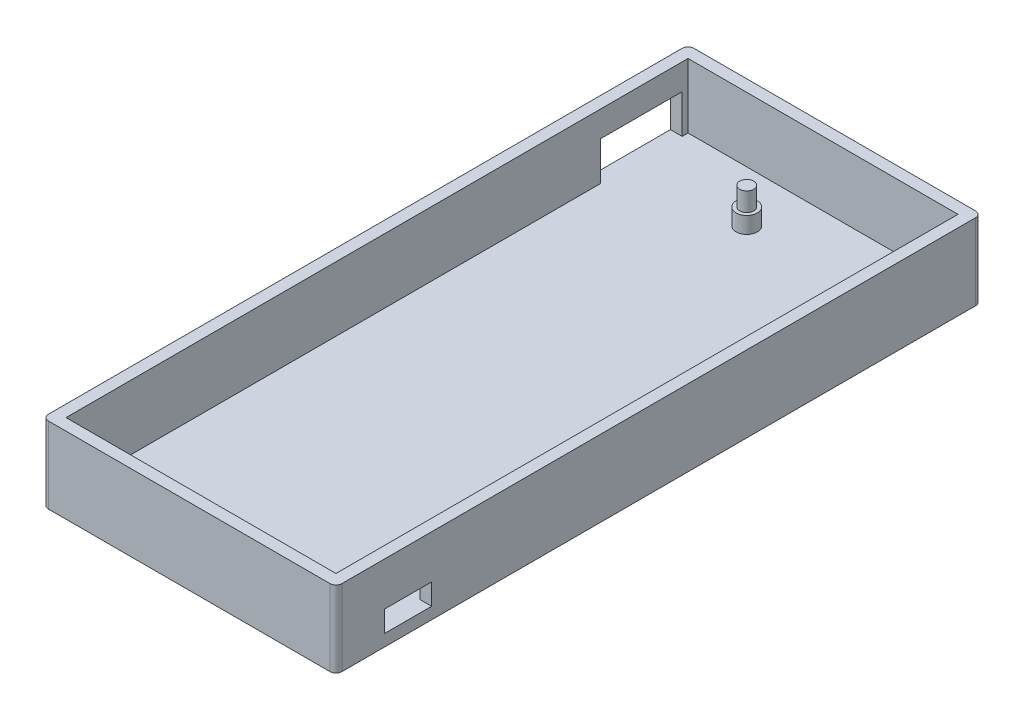
from build123d import *

# Parameters (mm, degrees)
SKETCH1_W               = 50
SKETCH1_H               = 110
BOSS_EXTRUDE1_DEPTH     = 2
SKETCH2_W               = 50
SKETCH2_H               = 110
SKETCH2_W_2             = 46
SKETCH2_H_2             = 106
BOSS_EXTRUDE3_DEPTH     = 11
SKETCH3_R               = 1.2
BOSS_EXTRUDE4_DEPTH     = 11
SKETCH4_W               = 52
SKETCH4_H               = 112
SKETCH4_W_2             = 50
SKETCH4_H_2             = 110
EXTRUDE_THIN1_DEPTH     = 13
FILLET2_R               = 2
EXTRUDE_THIN3_DEPTH     = 3
SKETCH6_R               = 1.8
BOSS_EXTRUDE5_DEPTH     = 2.8
SKETCH8_W               = 8
SKETCH8_H               = 3.6
CUT_EXTRUDE2_DEPTH      = 12.8
SKETCH11_W              = 13.1
SKETCH11_H              = 5.8
CUT_EXTRUDE5_DEPTH      = 3
SKETCH13_W              = 108
SKETCH13_H              = 3
CUT_EXTRUDE6_DEPTH      = 70
CUT_EXTRUDE6_DEPTH_BACK = 40
SKETCH14_W              = 48
SKETCH14_H              = 3
CUT_EXTRUDE7_DEPTH      = 160
CUT_EXTRUDE7_DEPTH_BACK = 40
SKETCH15_W              = 66.867567733
SKETCH15_H              = 122.152543676
CUT_EXTRUDE8_DEPTH      = 40
SKETCH16_W              = 37.40524021
SKETCH16_H              = 102.153015582
CUT_EXTRUDE9_DEPTH      = 5
CUT_EXTRUDE_THIN2_DEPTH = 55
SKETCH18_W              = 13.9
SKETCH18_H              = 6.6
CUT_EXTRUDE10_DEPTH     = 2


with BuildPart() as part:
    # Sketch1 → Boss-Extrude1 (new body)
    with BuildSketch(Plane(origin=(0, 0, 0), x_dir=(1, 0, 0), z_dir=(0, 1, 0))):
        with Locations((-52.022587269, -1.919917864)):
            Rectangle(SKETCH1_W, SKETCH1_H)
    extrude(amount=BOSS_EXTRUDE1_DEPTH)

    # Sketch2 → Boss-Extrude3 (add)
    with BuildSketch(Plane(origin=(0, 2, 0), x_dir=(1, 0, 0), z_dir=(0, 1, 0))):
        with Locations((-52.022587269, -1.919917864)):
            Rectangle(SKETCH2_W, SKETCH2_H)
        with Locations((-52.022587269, -1.919917864)):
            Rectangle(SKETCH2_W_2, SKETCH2_H_2, mode=Mode.SUBTRACT)
    extrude(amount=BOSS_EXTRUDE3_DEPTH)

    # Sketch3 → Boss-Extrude4 (add)
    with BuildSketch(Plane(origin=(0, 2, 0), x_dir=(1, 0, 0), z_dir=(0, 1, 0))):
        with Locations((-31.022587269, 42.380082136)):
            Circle(SKETCH3_R)
        with Locations((-31.022587269, -52.919917864)):
            Circle(SKETCH3_R)
        with Locations((-56.322587269, 42.380082136)):
            Circle(SKETCH3_R)
        with Locations((-56.322587269, -52.919917864)):
            Circle(SKETCH3_R)
    extrude(amount=BOSS_EXTRUDE4_DEPTH)

    # Sketch4 → Extrude-Thin1 (add)
    with BuildSketch(Plane(origin=(0, 13, 0), x_dir=(1, 0, 0), z_dir=(0, 1, 0))):
        with Locations((-52.022587269, -1.919917864)):
            Rectangle(SKETCH4_W, SKETCH4_H)
        with Locations((-52.022587269, -1.919917864)):
            Rectangle(SKETCH4_W_2, SKETCH4_H_2, mode=Mode.SUBTRACT)
    extrude(amount=-EXTRUDE_THIN1_DEPTH)

    # Fillet2
    fillet2_edges = [part.edges().sort_by_distance(p)[0] for p in [
        (-26.022587269, 6.5, -54.080082136),
        (-26.022587269, 6.5, 57.919917864),
        (-78.022587269, 6.5, 57.919917864),
        (-78.022587269, 6.5, -54.080082136),
    ]]
    fillet(fillet2_edges, radius=FILLET2_R)

    # Sketch5 → Extrude-Thin3 (add)
    with BuildSketch(Plane(origin=(0, 13, 0), x_dir=(1, 0, 0), z_dir=(0, 1, 0))):
        with BuildLine():
            Line((-28.022587269, 54.080082136), (-76.022587269, 54.080082136))
            ThreePointArc((-76.022587269, 54.080082136), (-77.436800831, 53.494295698), (-78.022587269, 52.080082136))
            Line((-78.022587269, 52.080082136), (-78.022587269, -55.919917864))
            ThreePointArc((-78.022587269, -55.919917864), (-77.436800831, -57.334131427), (-76.022587269, -57.919917864))
            Line((-76.022587269, -57.919917864), (-28.022587269, -57.919917864))
            ThreePointArc((-28.022587269, -57.919917864), (-26.608373707, -57.334131427), (-26.022587269, -55.919917864))
            Line((-26.022587269, -55.919917864), (-26.022587269, 52.080082136))
            ThreePointArc((-26.022587269, 52.080082136), (-26.608373707, 53.494295698), (-28.022587269, 54.080082136))
        make_face()
        with BuildLine():
            Line((-28.022587269, 52.880082136), (-76.022587269, 52.880082136))
            ThreePointArc((-76.022587269, 52.880082136), (-76.588272694, 52.64576756), (-76.822587269, 52.080082136))
            Line((-76.822587269, 52.080082136), (-76.822587269, -55.919917864))
            ThreePointArc((-76.822587269, -55.919917864), (-76.588272694, -56.485603289), (-76.022587269, -56.719917864))
            Line((-76.022587269, -56.719917864), (-28.022587269, -56.719917864))
            ThreePointArc((-28.022587269, -56.719917864), (-27.456901844, -56.485603289), (-27.222587269, -55.919917864))
            Line((-27.222587269, -55.919917864), (-27.222587269, 52.080082136))
            ThreePointArc((-27.222587269, 52.080082136), (-27.456901844, 52.64576756), (-28.022587269, 52.880082136))
        make_face(mode=Mode.SUBTRACT)
    extrude(amount=EXTRUDE_THIN3_DEPTH)

    # Sketch6 → Boss-Extrude5 (add)
    with BuildSketch(Plane(origin=(0, 2, 0), x_dir=(1, 0, 0), z_dir=(0, 1, 0))):
        with Locations((-56.322587269, -52.919917864)):
            Circle(SKETCH6_R)
        with Locations((-31.022587269, -52.919917864)):
            Circle(SKETCH6_R)
        with Locations((-56.322587269, 42.380082136)):
            Circle(SKETCH6_R)
        with Locations((-31.022587269, 42.380082136)):
            Circle(SKETCH6_R)
    extrude(amount=BOSS_EXTRUDE5_DEPTH)

    # Sketch8 → Cut-Extrude2 (cut)
    with BuildSketch(Plane(origin=(-26.022587269, 0, 0), x_dir=(0, 0, -1), z_dir=(1, 0, 0))):
        with Locations((-44.619917864, 3.8)):
            Rectangle(SKETCH8_W, SKETCH8_H)
    extrude(amount=-CUT_EXTRUDE2_DEPTH, mode=Mode.SUBTRACT)

    # Sketch11 → Cut-Extrude5 (cut)
    with BuildSketch(Plane.ZY.offset(78.022587269)):
        with Locations((-43.530082136, 4.9)):
            Rectangle(SKETCH11_W, SKETCH11_H)
    extrude(amount=-CUT_EXTRUDE5_DEPTH, mode=Mode.SUBTRACT)

    # Sketch13 → Cut-Extrude6 (cut, two sides)
    with BuildSketch(Plane(origin=(-76.822587269, 0, 0), x_dir=(0, 0, -1), z_dir=(1, 0, 0))) as cut_extrude6_sk:
        with Locations((-1.919917864, 14.5)):
            Rectangle(SKETCH13_W, SKETCH13_H)
    extrude(amount=CUT_EXTRUDE6_DEPTH, mode=Mode.SUBTRACT)
    extrude(cut_extrude6_sk.sketch, amount=-CUT_EXTRUDE6_DEPTH_BACK, mode=Mode.SUBTRACT)

    # Sketch14 → Cut-Extrude7 (cut, two sides)
    with BuildSketch(Plane.XY.offset(-52.880082136)) as cut_extrude7_sk:
        with Locations((-52.022587269, 14.5)):
            Rectangle(SKETCH14_W, SKETCH14_H)
    extrude(amount=CUT_EXTRUDE7_DEPTH, mode=Mode.SUBTRACT)
    extrude(cut_extrude7_sk.sketch, amount=-CUT_EXTRUDE7_DEPTH_BACK, mode=Mode.SUBTRACT)

    # Sketch15 → Cut-Extrude8 (cut)
    with BuildSketch(Plane(origin=(0, 13, 0), x_dir=(1, 0, 0), z_dir=(0, 1, 0))):
        with Locations((-54.115240408, -0.313928246)):
            Rectangle(SKETCH15_W, SKETCH15_H)
    extrude(amount=CUT_EXTRUDE8_DEPTH, mode=Mode.SUBTRACT)

    # Sketch16 → Cut-Extrude9 (cut)
    with BuildSketch(Plane(origin=(0, 13, 0), x_dir=(1, 0, 0), z_dir=(0, 1, 0))):
        with Locations((-47.725207374, -3.843410073)):
            Rectangle(SKETCH16_W, SKETCH16_H)
    extrude(amount=-CUT_EXTRUDE9_DEPTH, mode=Mode.SUBTRACT)

    # Sketch17 → Cut-Extrude-Thin2 (cut)
    with BuildSketch(Plane(origin=(0, 13, 0), x_dir=(1, 0, 0), z_dir=(0, 1, 0))):
        with BuildLine():
            Line((-97.022587269, 52.080082136), (-97.022587269, -55.919917864))
            ThreePointArc((-97.022587269, -55.919917864), (-90.871829674, -70.769160269), (-76.022587269, -76.919917864))
            Line((-76.022587269, -76.919917864), (-28.022587269, -76.919917864))
            ThreePointArc((-28.022587269, -76.919917864), (-13.173344864, -70.769160269), (-7.022587269, -55.919917864))
            Line((-7.022587269, -55.919917864), (-7.022587269, 52.080082136))
            ThreePointArc((-7.022587269, 52.080082136), (-13.173344864, 66.92932454), (-28.022587269, 73.080082136))
            Line((-28.022587269, 73.080082136), (-76.022587269, 73.080082136))
            ThreePointArc((-76.022587269, 73.080082136), (-90.871829674, 66.92932454), (-97.022587269, 52.080082136))
        make_face()
        with BuildLine():
            Line((-77.022587269, 52.080082136), (-77.022587269, -55.919917864))
            ThreePointArc((-77.022587269, -55.919917864), (-76.72969405, -56.627024646), (-76.022587269, -56.919917864))
            Line((-76.022587269, -56.919917864), (-28.022587269, -56.919917864))
            ThreePointArc((-28.022587269, -56.919917864), (-27.315480488, -56.627024646), (-27.022587269, -55.919917864))
            Line((-27.022587269, -55.919917864), (-27.022587269, 52.080082136))
            ThreePointArc((-27.022587269, 52.080082136), (-27.315480488, 52.787188917), (-28.022587269, 53.080082136))
            Line((-28.022587269, 53.080082136), (-76.022587269, 53.080082136))
            ThreePointArc((-76.022587269, 53.080082136), (-76.72969405, 52.787188917), (-77.022587269, 52.080082136))
        make_face(mode=Mode.SUBTRACT)
    extrude(amount=-CUT_EXTRUDE_THIN2_DEPTH, mode=Mode.SUBTRACT)

    # Sketch18 → Cut-Extrude10 (cut)
    with BuildSketch(Plane.ZY.offset(77.022587269)):
        with Locations((-43.130082136, 5.3)):
            Rectangle(SKETCH18_W, SKETCH18_H)
    extrude(amount=-CUT_EXTRUDE10_DEPTH, mode=Mode.SUBTRACT)


solid = part.part
